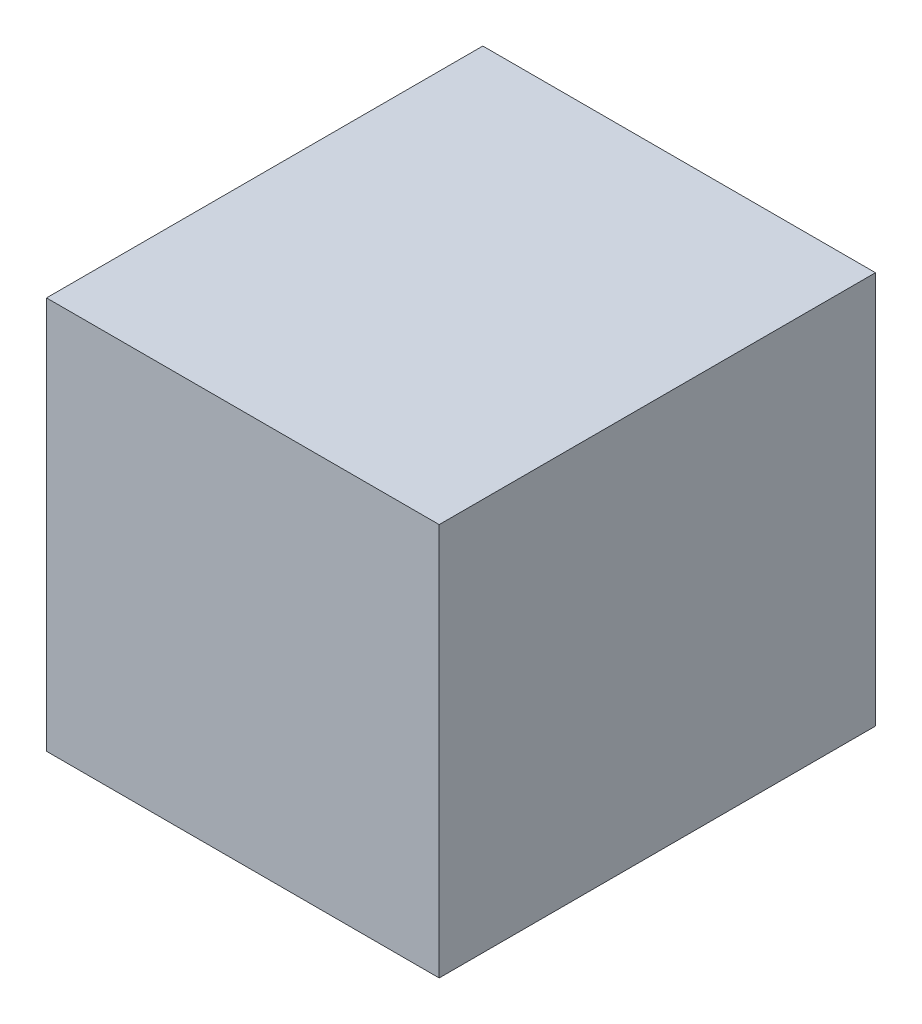
from build123d import *

# Parameters (mm, degrees)
SZKIC1_W                    = 43.2
SZKIC1_H                    = 43.2
DODANIE_WYCI_GNI_CIE1_DEPTH = 48


with BuildPart() as part:
    # Szkic1 → Dodanie-wyciągnięcie1 (new body)
    with BuildSketch(Plane.XY):
        Rectangle(SZKIC1_W, SZKIC1_H)
    extrude(amount=DODANIE_WYCI_GNI_CIE1_DEPTH)


solid = part.part
